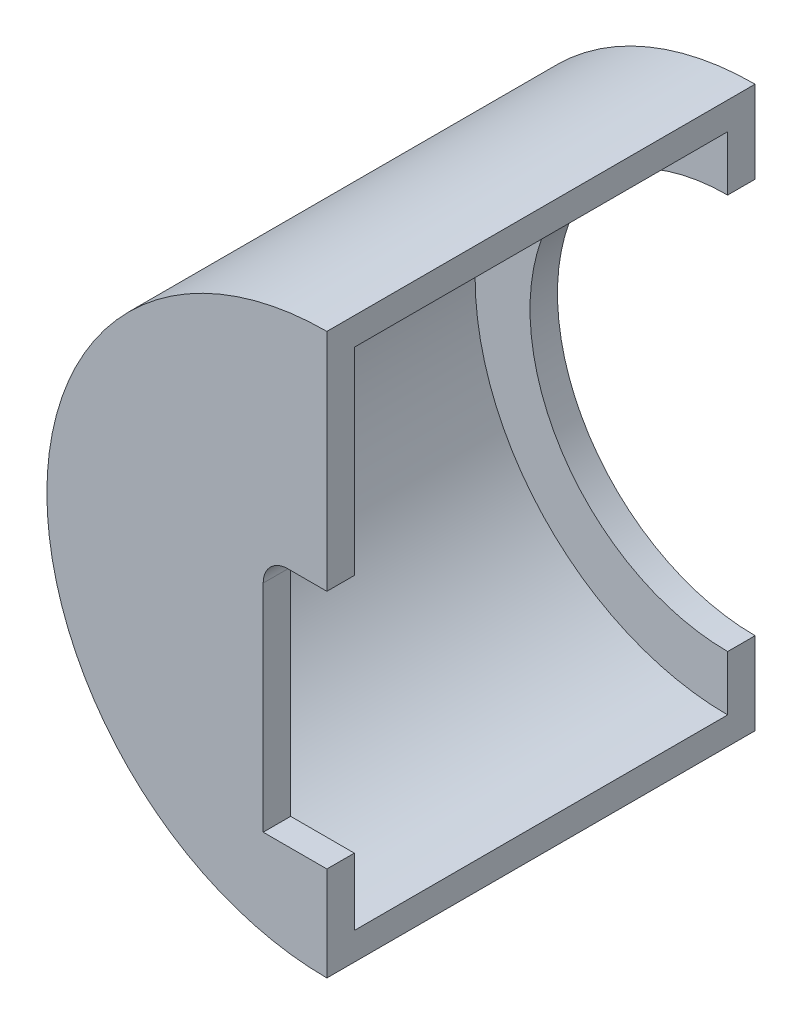
from build123d import *

# Parameters (mm, degrees)
BOSS_EXTRU_1_DEPTH      = 34
BOSS_EXTRU_2_DEPTH      = 5
BOSS_EXTRU_3_DEPTH      = 5
ENL_V_MAT_EXTRU_1_DEPTH = 10


with BuildPart() as part:
    # Esquisse1 → Boss.-Extru.1 (new body, symmetric)
    with BuildSketch(Plane.XY):
        with BuildLine():
            Line((0, 51), (0, 46))
            ThreePointArc((0, 46), (-46, 0), (0, -46))
            Line((0, -46), (0, -51))
            ThreePointArc((0, -51), (-51, 0), (0, 51))
        make_face()
    extrude(amount=BOSS_EXTRU_1_DEPTH, both=True)

    # Esquisse2 → Boss.-Extru.2 (add)
    with BuildSketch(Plane.XY.offset(34)):
        with BuildLine():
            Line((0, 51), (0, -51))
            ThreePointArc((0, -51), (-51, 0), (0, 51))
        make_face()
    extrude(amount=BOSS_EXTRU_2_DEPTH)

    # Esquisse3 → Boss.-Extru.3 (add)
    with BuildSketch(Plane(origin=(0, 0, -34), x_dir=(-1, 0, 0), z_dir=(0, 0, -1))):
        with BuildLine():
            Line((0, 51), (0, 36))
            ThreePointArc((0, 36), (36, 0), (0, -36))
            Line((0, -36), (0, -51))
            ThreePointArc((0, -51), (51, 0), (0, 51))
        make_face()
    extrude(amount=BOSS_EXTRU_3_DEPTH)

    # Esquisse4 → Enlèv. mat.-Extru.1 (cut)
    with BuildSketch(Plane.XY.offset(39)):
        with BuildLine():
            Line((-11.59999996, 5.499999956), (-11.59999996, -2))
            Line((-11.59999996, -2), (-0.788986692, -2))
            ThreePointArc((-0.788986692, -2), (-2.112167134, 0.40155946), (0, 2.15))
            Line((0, 2.15), (0, 10.000000044))
            Line((0, 10.000000044), (-7.099999871, 10.000000044))
            ThreePointArc((-7.099999871, 10.000000044), (-10.281980449, 8.681980534), (-11.59999996, 5.499999956))
        make_face()
        with BuildLine():
            ThreePointArc((0, 2.15), (-2.112167134, 0.40155946), (-0.788986692, -2))
            Line((-0.788986692, -2), (0, -2))
            Line((0, -2), (0, 2.15))
        make_face()
        with BuildLine():
            Line((0, -2), (-0.788986692, -2))
            ThreePointArc((-0.788986692, -2), (-0.40155946, -2.112167134), (0, -2.15))
            Line((0, -2.15), (0, -2))
        make_face()
        with BuildLine():
            Line((0, 2.15), (0, -2))
            Line((0, -2), (0.788986692, -2))
            ThreePointArc((0.788986692, -2), (1.77747312, -1.209582286), (2.15, 0))
            ThreePointArc((2.15, 0), (1.52027958, 1.52027958), (0, 2.15))
        make_face()
        with BuildLine():
            Line((0.788986692, -2), (0, -2))
            Line((0, -2), (0, -2.15))
            ThreePointArc((0, -2.15), (0.40155946, -2.112167134), (0.788986692, -2))
        make_face()
        with BuildLine():
            Line((-0.788986692, -2), (-11.59999996, -2))
            Line((-11.59999996, -2), (-11.59999996, -33.8))
            Line((-11.59999996, -33.8), (0, -33.8))
            Line((0, -33.8), (0, -2.15))
            ThreePointArc((0, -2.15), (-0.40155946, -2.112167134), (-0.788986692, -2))
        make_face()
    extrude(amount=-ENL_V_MAT_EXTRU_1_DEPTH, mode=Mode.SUBTRACT)


solid = part.part
